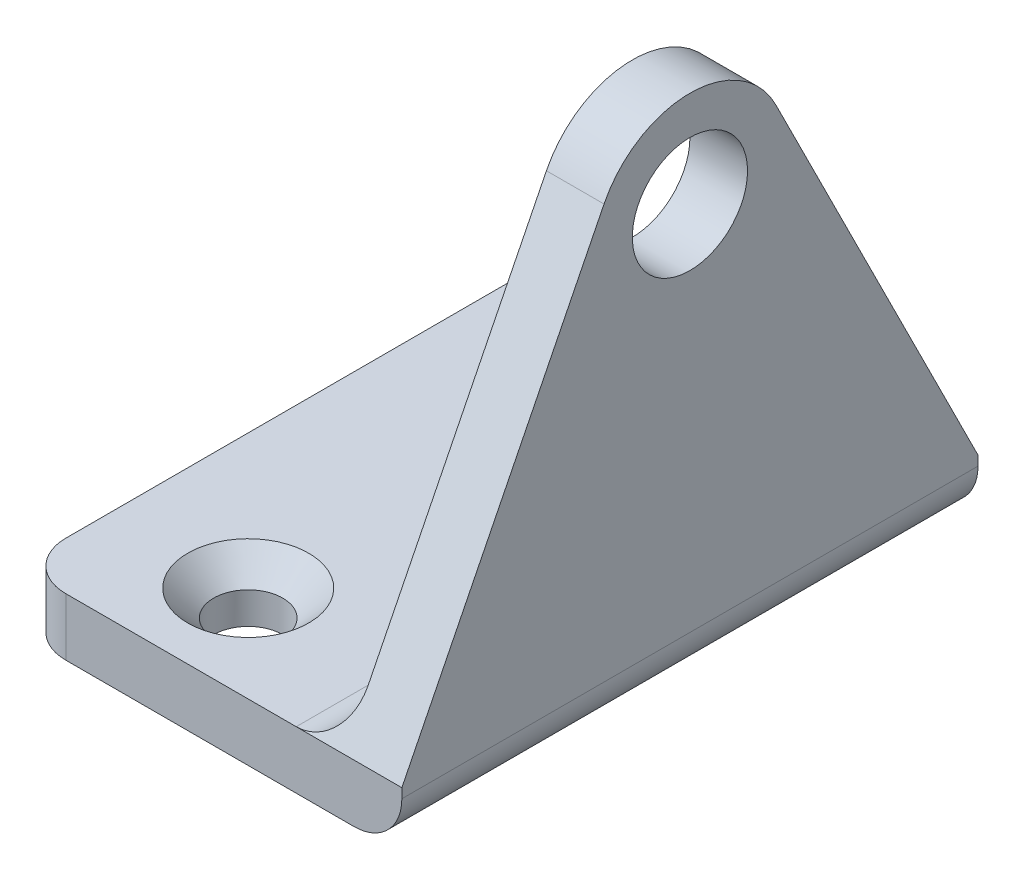
from build123d import *

# Parameters (mm, degrees)
SKETCH1_W                                       = 20
SKETCH1_H                                       = 30
BOSS_EXTRUDE1_DEPTH                             = 3
SKETCH3_R                                       = 3
BOSS_EXTRUDE2_DEPTH                             = 3
FILLET1_R                                       = 2.5
CSK_FOR_M3_FLAT_HEAD_MACHINE_SCREW1_D           = 3.6
CSK_FOR_M3_FLAT_HEAD_MACHINE_SCREW1_DEPTH       = 5
CSK_FOR_M3_FLAT_HEAD_MACHINE_SCREW1_CSINK_D     = 6.3
CSK_FOR_M3_FLAT_HEAD_MACHINE_SCREW1_CSINK_ANGLE = 90
CSK_FOR_M3_FLAT_HEAD_MACHINE_SCREW1_TIP         = 1.081549114
FILLET2_R                                       = 2.5


with BuildPart() as part:
    # Sketch1 → Boss-Extrude1 (new body)
    with BuildSketch(Plane(origin=(0, 0, 0), x_dir=(1, 0, 0), z_dir=(0, 1, 0))):
        Rectangle(SKETCH1_W, SKETCH1_H)
    extrude(amount=BOSS_EXTRUDE1_DEPTH)

    # Sketch3 → Boss-Extrude2 (add)
    with BuildSketch(Plane(origin=(10, 0, 0), x_dir=(0, 0, -1), z_dir=(1, 0, 0))):
        with BuildLine():
            ThreePointArc((-4.472135955, 24.05572809), (0, 26.819660113), (4.472135955, 24.05572809))
            Line((4.472135955, 24.05572809), (15, 3))
            Line((15, 3), (-15, 3))
            Line((-15, 3), (-4.472135955, 24.05572809))
        make_face()
        with Locations((0, 21.819660113)):
            Circle(SKETCH3_R, mode=Mode.SUBTRACT)
    extrude(amount=-BOSS_EXTRUDE2_DEPTH)

    # Fillet1
    fillet1_edges = [part.edges().sort_by_distance(p)[0] for p in [
        (10, 0, 0),
        (-10, 1.5, -15),
        (-10, 1.5, 15),
    ]]
    fillet(fillet1_edges, radius=FILLET1_R)

    # CSK for M3 Flat Head Machine Screw1
    with Locations(Plane(origin=(0, 3, 0), x_dir=(1, 0, 0), z_dir=(0, 1, 0))):
        with Locations((-3, 10), (-3, -10)):
            CounterSinkHole(CSK_FOR_M3_FLAT_HEAD_MACHINE_SCREW1_D / 2, CSK_FOR_M3_FLAT_HEAD_MACHINE_SCREW1_CSINK_D / 2, depth=CSK_FOR_M3_FLAT_HEAD_MACHINE_SCREW1_DEPTH, counter_sink_angle=CSK_FOR_M3_FLAT_HEAD_MACHINE_SCREW1_CSINK_ANGLE)
            with Locations((0, 0, -(CSK_FOR_M3_FLAT_HEAD_MACHINE_SCREW1_DEPTH + CSK_FOR_M3_FLAT_HEAD_MACHINE_SCREW1_TIP / 2))):  # 118° drill point
                Cone(0, CSK_FOR_M3_FLAT_HEAD_MACHINE_SCREW1_D / 2, CSK_FOR_M3_FLAT_HEAD_MACHINE_SCREW1_TIP, mode=Mode.SUBTRACT)

    # Fillet2
    fillet2_edges = [part.edges().sort_by_distance(p)[0] for p in [
        (7, 3, 0),
    ]]
    fillet(fillet2_edges, radius=FILLET2_R)


solid = part.part
